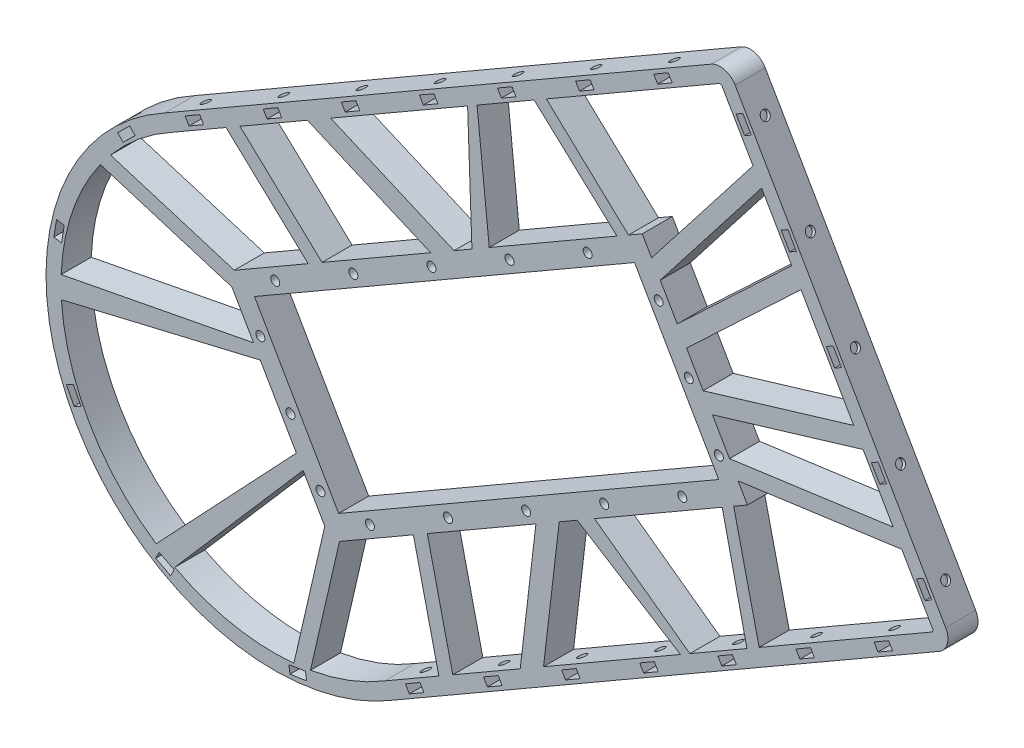
from build123d import *

# Parameters (mm, degrees)
SKETCH_1_R               = 1.5
SKETCH_1_R_2             = 69.25
EXTRUDE_1_DEPTH          = 3
SKETCH_2_R               = 1.5
CUT_EXTRUDE_1_DEPTH      = 10
EXTRUDE_4_DEPTH          = 30
SKETCH_21_R              = 1.5
CUT_EXTRUDE_16_DEPTH     = 264.511765735
SKETCH_22_R              = 1.5
CUT_EXTRUDE_17_DEPTH     = 15
EXTRUDE_5_DEPTH          = 13
SKETCH_25_R              = 1.5
CUT_EXTRUDE_18_DEPTH     = 8
SKETCH_26_R              = 1.5
CUT_EXTRUDE_19_DEPTH     = 265
EXTRUDE_6_DEPTH          = 10
CUT_EXTRUDE_20_DEPTH     = 265
EXTRUDE_8_DEPTH          = 10
SKETCH_31_R              = 1.5
CUT_EXTRUDE_22_DEPTH     = 265
SKETCH_32_W              = 406.044805538
SKETCH_32_H              = 345.897022528
CUT_EXTRUDE_23_DEPTH     = 265
CUT_EXTRUDE_24_DEPTH     = 3
CUT_EXTRUDE_27_DEPTH     = 22
SKETCH_35_R              = 1.5
CUT_EXTRUDE_28_DEPTH     = 12
PATTERN_CIRCULAR_1_COUNT = 5
PATTERN_CIRCULAR_1_ANGLE = 144


with BuildPart() as part:
    # Sketch 1 → Extrude 1 (new body)
    with BuildSketch(Plane.XY):
        with BuildLine():
            Line((-22.769302312, -105.521905889), (96.897661611, -36.432152055))
            Line((96.897661611, -36.432152055), (159.096032483, -0.521905889))
            ThreePointArc((159.096032483, -0.521905889), (163.755290746, 5.550157697), (162.756286521, 13.138348148))
            Line((162.756286521, 13.138348148), (92.756286521, 134.381904678))
            ThreePointArc((92.756286521, 134.381904678), (86.684222934, 139.041162941), (79.096032483, 138.042158716))
            Line((79.096032483, 138.042158716), (16.897661611, 102.13191255))
            Line((16.897661611, 102.13191255), (-102.769302312, 33.042158716))
            ThreePointArc((-102.769302312, 33.042158716), (-133.627927222, -77.150119753), (-22.769302312, -105.521905889))
        make_face()
        with Locations((0, 74.563800918)):
            Circle(SKETCH_1_R, mode=Mode.SUBTRACT)
        with Locations((64.574145798, -37.281900459)):
            Circle(SKETCH_1_R, mode=Mode.SUBTRACT)
        with Locations((-64.574145798, -37.281900459)):
            Circle(SKETCH_1_R, mode=Mode.SUBTRACT)
        Circle(SKETCH_1_R_2, mode=Mode.SUBTRACT)
    extrude(amount=EXTRUDE_1_DEPTH)

    # Sketch 2 → Cut-Extrude 1 (cut)
    with BuildSketch(Plane(origin=(0, 0, 0), x_dir=(-1, 0, 0), z_dir=(0, 0, -1))):
        with Locations((-109.955016331, 4.59283082)):
            Circle(SKETCH_2_R)
        with Locations((-130.739626022, 16.59283082)):
            Circle(SKETCH_2_R)
        with Locations((-58.955016331, 92.927422006)):
            Circle(SKETCH_2_R)
        with Locations((-79.739626022, 104.927422006)):
            Circle(SKETCH_2_R)
    extrude(amount=-CUT_EXTRUDE_1_DEPTH, mode=Mode.SUBTRACT)

    # Sketch 20 → Extrude 4 (add)
    with BuildSketch(Plane(origin=(0, 0, 0), x_dir=(-1, 0, 0), z_dir=(0, 0, -1))):
        with BuildLine():
            Line((-92.756286521, 134.381904678), (-162.756286521, 13.138348148))
            ThreePointArc((-162.756286521, 13.138348148), (-163.755290746, 5.550157697), (-159.096032483, -0.521905889))
            Line((-159.096032483, -0.521905889), (22.769302312, -105.521905889))
            ThreePointArc((22.769302312, -105.521905889), (133.627927222, -77.150119753), (102.769302312, 33.042158716))
            Line((102.769302312, 33.042158716), (-79.096032483, 138.042158716))
            ThreePointArc((-79.096032483, 138.042158716), (-86.684222934, 139.041162941), (-92.756286521, 134.381904678))
        make_face()
        with BuildLine():
            Line((-89.292184905, 132.381904678), (-159.292184905, 11.138348148))
            ThreePointArc((-159.292184905, 11.138348148), (-159.89158744, 6.585433878), (-157.096032483, 2.942195726))
            Line((-157.096032483, 2.942195726), (24.808773358, -102.080592893))
            ThreePointArc((24.808773358, -102.080592893), (130.163825607, -75.150119753), (100.808773358, 29.555268482))
            Line((100.808773358, 29.555268482), (-81.096032483, 134.578057101))
            ThreePointArc((-81.096032483, 134.578057101), (-85.648946753, 135.177459636), (-89.292184905, 132.381904678))
        make_face(mode=Mode.SUBTRACT)
    extrude(amount=EXTRUDE_4_DEPTH)

    # Sketch 21 → Cut-Extrude 16 (cut, through all)
    with BuildSketch(Plane(origin=(-40, 69.282032303, 0), x_dir=(0.866025404, 0.5, 0), z_dir=(-0.5, 0.866025404, 0))):
        with Locations((-62.479747173, 25)):
            Circle(SKETCH_21_R)
        with Locations((-32.479747173, 25)):
            Circle(SKETCH_21_R)
        with Locations((-2.479747173, 25)):
            Circle(SKETCH_21_R)
        with Locations((27.520252827, 25)):
            Circle(SKETCH_21_R)
        with Locations((57.520252827, 25)):
            Circle(SKETCH_21_R)
        with Locations((87.520252827, 25)):
            Circle(SKETCH_21_R)
        with Locations((117.520252827, 25)):
            Circle(SKETCH_21_R)
    extrude(amount=-CUT_EXTRUDE_16_DEPTH, mode=Mode.SUBTRACT)

    # Sketch 22 → Cut-Extrude 17 (cut)
    with BuildSketch(Plane(origin=(127.756286521, 73.760126413, 0), x_dir=(0, 0, -1), z_dir=(0.866025404, 0.5, 0))):
        with Locations((25, 60)):
            Circle(SKETCH_22_R)
        with Locations((25, 30)):
            Circle(SKETCH_22_R)
        with Locations((25, 0)):
            Circle(SKETCH_22_R)
        with Locations((25, -30)):
            Circle(SKETCH_22_R)
        with Locations((25, -60)):
            Circle(SKETCH_22_R)
    extrude(amount=-CUT_EXTRUDE_17_DEPTH, mode=Mode.SUBTRACT)

    # Sketch 23 → Extrude 5 (add)
    with BuildSketch(Plane(origin=(0, 0, 0), x_dir=(-1, 0, 0), z_dir=(0, 0, -1))):
        with BuildLine():
            Line((100.710773859, 29.380908411), (-81.196032483, 134.40485202))
            ThreePointArc((-81.196032483, 134.40485202), (-85.597182944, 134.984274471), (-89.118979825, 132.281904678))
            Line((-89.118979825, 132.281904678), (-159.118979825, 11.038348148))
            ThreePointArc((-159.118979825, 11.038348148), (-159.698402275, 6.637197687), (-156.996032483, 3.115400806))
            Line((-156.996032483, 3.115400806), (24.910773859, -101.908542802))
            ThreePointArc((24.910773859, -101.908542802), (129.990620526, -75.050119753), (100.710773859, 29.380908411))
        make_face()
        with BuildLine():
            Line((98.261672903, 25.021394816), (-83.696032483, 130.074725001))
            ThreePointArc((-83.696032483, 130.074725001), (-84.303087719, 130.154645339), (-84.788852806, 129.781904678))
            Line((-84.788852806, 129.781904678), (-154.788852806, 8.538348148))
            ThreePointArc((-154.788852806, 8.538348148), (-154.868773144, 7.931292912), (-154.496032483, 7.445527825))
            Line((-154.496032483, 7.445527825), (27.461672903, -97.60780236))
            ThreePointArc((27.461672903, -97.60780236), (125.660493508, -72.550119753), (98.261672903, 25.021394816))
        make_face(mode=Mode.SUBTRACT)
    extrude(amount=-EXTRUDE_5_DEPTH)

    # Sketch 25 → Cut-Extrude 18 (cut)
    with BuildSketch(Plane(origin=(124.118979825, 71.660126413, 0), x_dir=(0, 0, -1), z_dir=(0.866025404, 0.5, 0))):
        with Locations((-8, 60)):
            Circle(SKETCH_25_R)
        with Locations((-8, 30)):
            Circle(SKETCH_25_R)
        with Locations((-8, 0)):
            Circle(SKETCH_25_R)
        with Locations((-8, -30)):
            Circle(SKETCH_25_R)
        with Locations((-8, -60)):
            Circle(SKETCH_25_R)
    extrude(amount=-CUT_EXTRUDE_18_DEPTH, mode=Mode.SUBTRACT)

    # Sketch 26 → Cut-Extrude 19 (cut)
    with BuildSketch(Plane(origin=(-37.9, 65.644725607, 0), x_dir=(0.866025404, 0.5, 0), z_dir=(-0.5, 0.866025404, 0))):
        with Locations((-62.479747173, -8)):
            Circle(SKETCH_26_R)
        with Locations((-32.479747173, -8)):
            Circle(SKETCH_26_R)
        with Locations((-2.479747173, -8)):
            Circle(SKETCH_26_R)
        with Locations((27.520252827, -8)):
            Circle(SKETCH_26_R)
        with Locations((57.520252827, -8)):
            Circle(SKETCH_26_R)
        with Locations((87.520252827, -8)):
            Circle(SKETCH_26_R)
        with Locations((117.520252827, -8)):
            Circle(SKETCH_26_R)
    extrude(amount=-CUT_EXTRUDE_19_DEPTH, mode=Mode.SUBTRACT)

    # Sketch 27 → Extrude 6 (add)
    with BuildSketch(Plane.XY.offset(3)):
        Polygon((-45.361672903, -66.604092905), (93.202391703, 13.395907095), (58.202391703, 74.01768536), (-80.361672903, -5.98231464), align=None)
        Polygon((55.640213876, 64.455507534), (83.640213876, 15.958084922), (-42.799495076, -57.041915078), (-70.799495076, -8.544492466), align=None, mode=Mode.SUBTRACT)
    extrude(amount=EXTRUDE_6_DEPTH)

    # Sketch 28 → Cut-Extrude 20 (cut)
    with BuildSketch(Plane.XY.offset(13)):
        Polygon((-15.72564869, -92.217646268), (-14.42564869, -94.469312318), (-19.275390952, -97.269312318), (-20.575390952, -95.017646268), align=None)
        Polygon((6.705371162, -82.269312318), (11.555113423, -79.469312318), (10.255113423, -77.217646268), (5.405371162, -80.017646268), align=None)
        Polygon((32.686133275, -67.269312318), (37.535875537, -64.469312318), (36.235875537, -62.217646268), (31.386133275, -65.017646268), align=None)
        Polygon((58.666895389, -52.269312318), (63.51663765, -49.469312318), (62.21663765, -47.217646268), (57.366895389, -50.017646268), align=None)
        Polygon((84.647657503, -37.269312318), (89.497399764, -34.469312318), (88.197399764, -32.217646268), (83.347657503, -35.017646268), align=None)
        Polygon((110.628419616, -22.269312318), (115.478161877, -19.469312318), (114.178161877, -17.217646268), (109.328419616, -20.017646268), align=None)
        Polygon((136.60918173, -7.269312318), (141.458923991, -4.469312318), (140.158923991, -2.217646268), (135.30918173, -5.017646268), align=None)
        Polygon((63.30918173, 119.690011877), (62.00918173, 121.941677927), (66.858923991, 124.741677927), (68.158923991, 122.490011877), align=None)
        Polygon((37.328419616, 104.690011877), (36.028419616, 106.941677927), (40.878161877, 109.741677927), (42.178161877, 107.490011877), align=None)
        Polygon((11.347657503, 89.690011877), (10.047657503, 91.941677927), (14.897399764, 94.741677927), (16.197399764, 92.490011877), align=None)
        Polygon((-14.633104611, 74.690011877), (-15.933104611, 76.941677927), (-11.08336235, 79.741677927), (-9.78336235, 77.490011877), align=None)
        Polygon((-40.613866724, 59.690011877), (-41.913866724, 61.941677927), (-37.064124463, 64.741677927), (-35.764124463, 62.490011877), align=None)
        Polygon((-93.875390952, 31.941677927), (-89.02564869, 34.741677927), (-87.72564869, 32.490011877), (-92.575390952, 29.690011877), align=None)
        Polygon((-66.594628838, 44.690011877), (-67.894628838, 46.941677927), (-63.044886577, 49.741677927), (-61.744886577, 47.490011877), align=None)
        Polygon((149.42808329, 20.223473317), (152.22808329, 15.373731056), (154.47974934, 16.673731056), (151.67974934, 21.523473317), align=None)
        Polygon((139.47974934, 42.654493169), (136.67974934, 47.50423543), (134.42808329, 46.20423543), (137.22808329, 41.354493169), align=None)
        Polygon((124.47974934, 68.635255283), (121.67974934, 73.484997544), (119.42808329, 72.184997544), (122.22808329, 67.335255283), align=None)
        Polygon((109.47974934, 94.616017396), (106.67974934, 99.465759657), (104.42808329, 98.165759657), (107.22808329, 93.316017396), align=None)
        Polygon((94.47974934, 120.59677951), (91.67974934, 125.446521771), (89.42808329, 124.146521771), (92.22808329, 119.29677951), align=None)
    extrude(amount=-CUT_EXTRUDE_20_DEPTH, mode=Mode.SUBTRACT)

    # Sketch 30 → Extrude 8 (add)
    with BuildSketch(Plane.XY.offset(13)):
        Polygon((112.068054668, 85.310371985), (107.922916101, 89.712531664), (68.135584713, 52.248192829), (71.241913135, 46.867874176), align=None)
        Polygon((98.950505999, 108.394899743), (96.406644359, 113.779322647), (59.34542331, 66.089123081), (62.213357562, 61.121715243), align=None)
        Polygon((24.331505485, 98.768362958), (19.708497886, 96.891947732), (53.142901297, 66.089123081), (55.972189919, 69.160126413), align=None)
        Polygon((2.949445409, 86.456661235), (0, 84.758307493), (1.655787903, 38.106211971), (7.724521177, 40.569427371), align=None)
        Polygon((-1.747976688, 36.718440517), (-50.523677842, 57.700122779), (-54.943097479, 51.790017141), (-9.512673828, 32.247361853), align=None)
        Polygon((-45.889743184, 10.259239907), (-76.964412717, 39.337819671), (-81.650646335, 36.718440517), (-50.523677842, 7.590921232), align=None)
        Polygon((-73.350083184, -11.065799194), (-73.350083184, -5.618546996), (-120.801864013, 8.92508057), (-124.763106008, 4.691920389), align=None)
        Polygon((-66.087162089, -25.245346168), (-69.124877332, -21.644521246), (-136.839384074, -34.709590506), (-136.839384074, -42.002122059), align=None)
        Polygon((-53.307143918, -49.04163918), (-54.906692153, -44.610488149), (-104.794596754, -97.505321817), (-98.479079171, -101.151587593), align=None)
        Polygon((-41.540846023, -60.713761909), (-46.258304807, -57.99013581), (-58.318230755, -110.393979453), (-52.671585502, -109.080023344), align=None)
        Polygon((-18.687908296, -47.55024912), (-9.026220892, -89.07075422), (-4.414655194, -86.322046436), (-14.060109209, -44.871303324), align=None)
        Polygon((23.170697656, -24.36189812), (17.379921767, -73.477126749), (24.707933207, -72.604849894), (30.925113931, -19.873012476), align=None)
        Polygon((73.402847471, -42.379153747), (76.34838766, -40.674035966), (38.996415308, -13.595082114), (33.82884156, -17.619151598), align=None)
        Polygon((93.765137101, -31.377914027), (97.701664154, -28.312479616), (87.880521362, 13.893275169), (83.80631015, 12.978541014), align=None)
        Polygon((146.739106017, 26.600941785), (143.347989818, 31.496202041), (84.039636905, 23.317490482), (86.907571157, 18.350082644), align=None)
        Polygon((131.65478951, 48.607721162), (129.91497668, 54.398596303), (76.209726226, 38.263369501), (79.316054648, 32.883050848), align=None)
    extrude(amount=-EXTRUDE_8_DEPTH)

    # Sketch 31 → Cut-Extrude 22 (cut)
    with BuildSketch(Plane.XY.offset(13)):
        with Locations((-63.889241039, -0.513403553)):
            Circle(SKETCH_31_R)
        with Locations((-37.908478925, 14.486596447)):
            Circle(SKETCH_31_R)
        with Locations((-11.927716811, 29.486596447)):
            Circle(SKETCH_31_R)
        with Locations((14.053045302, 44.486596447)):
            Circle(SKETCH_31_R)
        with Locations((40.033807416, 59.486596447)):
            Circle(SKETCH_31_R)
        with Locations((-68.83058399, -18.954746504)):
            Circle(SKETCH_31_R)
        with Locations((-58.83058399, -36.27525458)):
            Circle(SKETCH_31_R)
        with Locations((-48.83058399, -53.595762655)):
            Circle(SKETCH_31_R)
        with Locations((83.671302789, 22.904237345)):
            Circle(SKETCH_31_R)
        with Locations((73.671302789, 40.22474542)):
            Circle(SKETCH_31_R)
        with Locations((63.671302789, 57.545253496)):
            Circle(SKETCH_31_R)
        with Locations((71.533807416, 4.926996009)):
            Circle(SKETCH_31_R)
        with Locations((45.553045302, -10.073003991)):
            Circle(SKETCH_31_R)
        with Locations((19.572283189, -25.073003991)):
            Circle(SKETCH_31_R)
        with Locations((-6.408478925, -40.073003991)):
            Circle(SKETCH_31_R)
        with Locations((-32.389241038, -55.073003991)):
            Circle(SKETCH_31_R)
    extrude(amount=-CUT_EXTRUDE_22_DEPTH, mode=Mode.SUBTRACT)

    # Sketch 32 → Cut-Extrude 23 (cut)
    with BuildSketch(Plane.XY.offset(3)):
        Rectangle(SKETCH_32_W, SKETCH_32_H)
    extrude(amount=-CUT_EXTRUDE_23_DEPTH, mode=Mode.SUBTRACT)

    # Sketch 33 → Cut-Extrude 24 (cut)
    with BuildSketch(Plane(origin=(0, 0, 3), x_dir=(-1, 0, 0), z_dir=(0, 0, -1))):
        Polygon((-15.74298901, 41.730254016), (-12.510954589, 41.64489105), (-10.821010881, 44.401233481), (-12.363101595, 47.242938878), (-15.595136015, 47.328301844), (-17.285079723, 44.571959413), align=None)
        Polygon((-41.723751123, 56.730254016), (-38.491716702, 56.64489105), (-36.801772995, 59.401233481), (-38.343863708, 62.242938878), (-41.575898129, 62.328301844), (-43.265841836, 59.571959413), align=None)
        Polygon((10.237773104, 26.730254016), (13.469807525, 26.64489105), (15.159751232, 29.401233481), (13.617660519, 32.242938878), (10.385626098, 32.328301844), (8.695682391, 29.571959413), align=None)
        Polygon((36.218535217, 11.730254016), (39.450569638, 11.64489105), (41.140513346, 14.401233481), (39.598422633, 17.242938878), (36.366388212, 17.328301844), (34.676444504, 14.571959413), align=None)
        Polygon((62.199297331, -3.269745984), (65.431331752, -3.35510895), (67.121275459, -0.598766519), (65.579184746, 2.242938878), (62.347150325, 2.328301844), (60.657206618, -0.428040587), align=None)
        Polygon((-70.741000749, 38.858486555), (-71.022936884, 42.079331995), (-73.953238924, 43.44559086), (-76.601604829, 41.591004286), (-76.319668695, 38.370158846), (-73.389366655, 37.00389998), align=None)
        Polygon((-60.741000749, 56.17899463), (-61.022936884, 59.399840071), (-63.953238924, 60.766098936), (-66.601604829, 58.911512361), (-66.319668695, 55.690666921), (-63.389366655, 54.324408056), align=None)
        Polygon((-80.741000749, 21.537978479), (-81.022936884, 24.758823919), (-83.953238924, 26.125082785), (-86.601604829, 24.27049621), (-86.319668695, 21.04965077), (-83.389366655, 19.683391904), align=None)
        Polygon((45.90028195, -54.962021521), (46.182218084, -51.741176081), (49.112520124, -50.374917215), (51.76088603, -52.22950379), (51.478949895, -55.45034923), (48.548647855, -56.816608096), align=None)
        Polygon((55.90028195, -37.641513445), (56.182218084, -34.420668005), (59.112520124, -33.05440914), (61.76088603, -34.908995714), (61.478949895, -38.129841154), (58.548647855, -39.49610002), align=None)
        Polygon((65.90028195, -20.32100537), (66.182218084, -17.100159929), (69.112520124, -15.733901064), (71.76088603, -17.588487639), (71.478949895, -20.809333079), (68.548647855, -22.175591944), align=None)
        Polygon((30.699297331, -52.31666156), (33.931331752, -52.231298594), (35.621275459, -54.987641025), (34.079184746, -57.829346423), (30.847150325, -57.914709389), (29.157206618, -55.158366957), align=None)
        Polygon((4.718535217, -37.31666156), (7.950569638, -37.231298594), (9.640513346, -39.987641025), (8.098422633, -42.829346423), (4.866388212, -42.914709389), (3.176444504, -40.158366957), align=None)
        Polygon((-21.262226896, -22.31666156), (-18.030192475, -22.231298594), (-16.340248768, -24.987641025), (-17.882339481, -27.829346423), (-21.114373902, -27.914709389), (-22.804317609, -25.158366957), align=None)
        Polygon((-47.24298901, -7.31666156), (-44.010954589, -7.231298594), (-42.321010881, -9.987641025), (-43.863101595, -12.829346423), (-47.095136015, -12.914709389), (-48.785079723, -10.158366957), align=None)
        Polygon((-73.223751123, 7.68333844), (-69.991716702, 7.768701406), (-68.301772995, 5.012358975), (-69.843863708, 2.170653577), (-73.075898129, 2.085290611), (-74.765841836, 4.841633043), align=None)
    extrude(amount=-CUT_EXTRUDE_24_DEPTH, mode=Mode.SUBTRACT)

    # Sketch 34 → Cut-Extrude 27 (cut)
    with BuildSketch(Plane(origin=(0, 0, 3), x_dir=(-1, 0, 0), z_dir=(0, 0, -1))):
        Polygon((110.496623709, 17.979143045), (114.46643325, 14.029382014), (116.300250872, 15.872507872), (112.33044133, 19.822268904), align=None)
        Polygon((134.07748456, -19.684702491), (134.967516659, -25.213521792), (137.534468477, -24.800292603), (136.644436378, -19.271473302), align=None)
        Polygon((131.01654878, -64.015875848), (128.486841426, -69.011932363), (130.806439094, -70.186439349), (133.336146448, -65.190382834), align=None)
        Polygon((102.4829898, -98.081375564), (97.49980522, -100.636345515), (98.686041269, -102.949966927), (103.669225848, -100.394996976), align=None)
        Polygon((59.375657329, -108.869338593), (53.842402661, -108.007310298), (53.442175238, -110.576321393), (58.975429906, -111.438349689), align=None)
    extrude(amount=-CUT_EXTRUDE_27_DEPTH, mode=Mode.SUBTRACT)

    # Sketch 35 → Cut-Extrude 28 (cut)
    with BuildSketch(Plane(origin=(15.151969184, -97.258645304, 0), x_dir=(0.988081191, 0.153933624, 0), z_dir=(0.153933624, -0.988081191, 0))):
        with Locations((-72.626622039, 8)):
            Circle(SKETCH_35_R)
    cut_extrude_28 = extrude(amount=CUT_EXTRUDE_28_DEPTH, mode=Mode.SUBTRACT)

    # Pattern Circular 1: Cut-Extrude 28 ×5 about axis
    pattern_circular_1_axis = Axis((-64.328355458, -37.13999334, 13), (0, 0, -1))
    for i in range(1, PATTERN_CIRCULAR_1_COUNT):
        add(cut_extrude_28.rotate(pattern_circular_1_axis, i * PATTERN_CIRCULAR_1_ANGLE / (PATTERN_CIRCULAR_1_COUNT - 1)), mode=Mode.SUBTRACT)


solid = part.part
